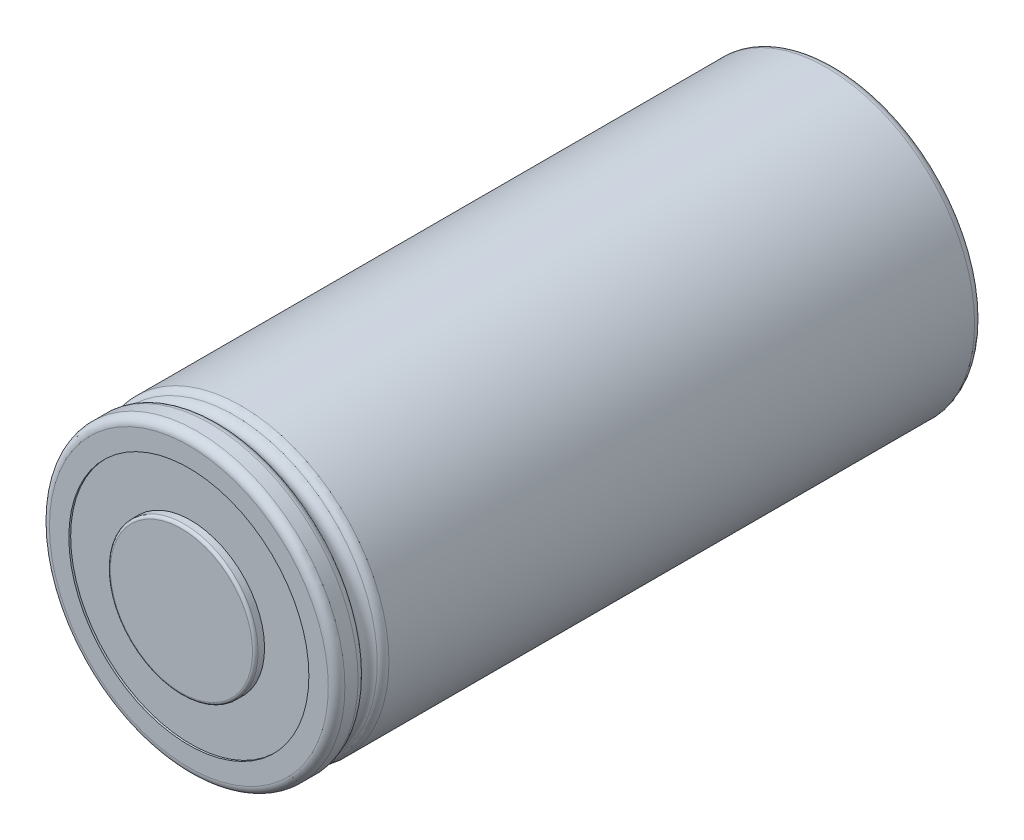
from build123d import *

# Parameters (mm, degrees)
SKETCH2_R           = 13
CUT_EXTRUDE1_DEPTH  = 0.2
SKETCH3_R           = 13
CUT_EXTRUDE2_DEPTH  = 0.2
SKETCH4_R           = 8
BOSS_EXTRUDE1_DEPTH = 1
FILLET1_R           = 0.3
FILLET2_R           = 0.9
BOSS_EXTRUDE2_DEPTH = 0.005


with BuildPart() as part:
    # Sketch1 → Revolve5 (revolve)
    with BuildSketch(Plane(origin=(0, 0, 0), x_dir=(1, 0, 0), z_dir=(0, 1, 0)), mode=Mode.PRIVATE) as revolve5_sk:
        with BuildLine():
            Line((-16, -70), (0, -70))
            Line((0, -70), (0, 0))
            Line((0, 0), (-16, 0))
            Line((-16, 0), (-16, -65))
            ThreePointArc((-16, -65), (-15, -66), (-16, -67))
            Line((-16, -67), (-16, -70))
        make_face()
    revolve(revolve5_sk.sketch.rotate(Axis((0, 0, 70), (0, 0, -1)), 180), axis=Axis((0, 0, 70), (0, 0, -1)))

    # Sketch2 → Cut-Extrude1 (cut)
    with BuildSketch(Plane.XY.offset(70)):
        Circle(SKETCH2_R)
    extrude(amount=-CUT_EXTRUDE1_DEPTH, mode=Mode.SUBTRACT)

    # Sketch3 → Cut-Extrude2 (cut)
    with BuildSketch(Plane(origin=(0, 0, 0), x_dir=(-1, 0, 0), z_dir=(0, 0, -1))):
        with Locations(Location((0, 0, 0), (0, 0, 180))):
            Circle(SKETCH3_R)
    extrude(amount=-CUT_EXTRUDE2_DEPTH, mode=Mode.SUBTRACT)

    # Sketch4 → Boss-Extrude1 (add)
    with BuildSketch(Plane.XY.offset(69.8)):
        Circle(SKETCH4_R)
    extrude(amount=BOSS_EXTRUDE1_DEPTH)

    # Fillet1
    fillet1_edges = [part.edges().sort_by_distance(p)[0] for p in [
        (-8, 0, 70.8),
    ]]
    fillet(fillet1_edges, radius=FILLET1_R)

    # Fillet2
    fillet2_edges = [part.edges().sort_by_distance(p)[0] for p in [
        (-16, 0, 67),
        (-16, 0, 65),
        (-16, 0, 0),
        (-16, 0, 70),
    ]]
    fillet(fillet2_edges, radius=FILLET2_R)

    # Sketch5 → Boss-Extrude2 (add)
    with BuildSketch(Plane(origin=(0, 0, 0.2), x_dir=(-1, 0, 0), z_dir=(0, 0, -1))):
        with BuildLine():
            add(Edge.make_bspline(
                [(12.463312382, 0.467916667), (12.463568751, 0.452915303), (12.464073588, 0.423374981), (12.461600059, 0.379635653), (12.455939689, 0.337394649), (12.447640097, 0.296916367), (12.437129889, 0.25884798), (12.425772381, 0.223332144), (12.413224809, 0.190672648), (12.403315309, 0.170422699), (12.398520715, 0.160625)],
                knots=[0, 0, 0, 0, 1.134571954, 2.234171624, 3.30983776, 4.355420189, 5.356944938, 6.295455342, 7.175276202, 8, 8, 8, 8], degree=3))
            Line((12.398520715, 0.160625), (12.449562382, 0.113958333))
            Line((12.449562382, 0.113958333), (12.451645715, 0.054166667))
            Line((12.451645715, 0.054166667), (12.091437382, 0.031666667))
            Line((12.091437382, 0.031666667), (12.089145715, 0.092083333))
            add(Edge.make_bspline(
                [(12.089145715, 0.092083333), (12.09772169, 0.09597062), (12.115237822, 0.103910269), (12.14143597, 0.117446952), (12.168570709, 0.131846926), (12.195785285, 0.148024142), (12.222680031, 0.165268593), (12.248366514, 0.183789782), (12.272468341, 0.203606103), (12.287358249, 0.217889477), (12.294770715, 0.225)],
                knots=[0, 0, 0, 0, 0.917927946, 1.874836081, 2.874577569, 3.912744782, 4.960757663, 5.988761967, 6.998769181, 8, 8, 8, 8], degree=3))
            add(Edge.make_bspline(
                [(12.294770715, 0.225), (12.302130885, 0.232514924), (12.316719814, 0.247410596), (12.336057478, 0.271811055), (12.35340353, 0.297141085), (12.36841561, 0.32377406), (12.380561834, 0.352073124), (12.388674224, 0.382573519), (12.392832691, 0.415158266), (12.392736689, 0.437489118), (12.392687382, 0.448958333)],
                knots=[0, 0, 0, 0, 0.99993657, 1.982019822, 2.956700106, 3.917788813, 4.885753513, 5.877584783, 6.909919021, 8, 8, 8, 8], degree=3))
            add(Edge.make_bspline(
                [(12.392687382, 0.448958333), (12.392334445, 0.456678119), (12.391644927, 0.47175992), (12.388419083, 0.493539407), (12.384013951, 0.513922037), (12.378602701, 0.532944297), (12.37113521, 0.550391394), (12.362485167, 0.566419038), (12.352326043, 0.580999925), (12.340959022, 0.594092489), (12.32835588, 0.605479666), (12.315239164, 0.61565025), (12.301216402, 0.62396817), (12.286556112, 0.630691623), (12.271187622, 0.635751719), (12.255110085, 0.639048869), (12.238349477, 0.640724554), (12.226996236, 0.640658536), (12.221229048, 0.640625)],
                knots=[0, 0, 0, 0, 1.278933472, 2.498595113, 3.639846239, 4.731350661, 5.767161868, 6.775743304, 7.742281868, 8.703951536, 9.639908856, 10.550662144, 11.447958886, 12.333014638, 13.216649933, 14.120992464, 15.045507072, 16, 16, 16, 16], degree=3))
            add(Edge.make_bspline(
                [(12.221229048, 0.640625), (12.211847888, 0.639775178), (12.193491295, 0.638112289), (12.167419697, 0.628780403), (12.143980894, 0.614052165), (12.123316749, 0.593592177), (12.104814981, 0.567739462), (12.088350519, 0.536159627), (12.073395385, 0.498841319), (12.065304254, 0.471674236), (12.061020715, 0.457291667)],
                knots=[0, 0, 0, 0, 0.859433942, 1.681698007, 2.507101058, 3.374700326, 4.325749461, 5.406370272, 6.626902341, 8, 8, 8, 8], degree=3))
            add(Edge.make_bspline(
                [(12.061020715, 0.457291667), (12.055598462, 0.438195845), (12.045186492, 0.401527486), (12.030248774, 0.348584126), (12.015779081, 0.299467678), (12.005152779, 0.268299938), (11.999979048, 0.253125)],
                knots=[0, 0, 0, 0, 1.117654491, 2.146153079, 3.097399687, 4, 4, 4, 4], degree=3))
            add(Edge.make_bspline(
                [(11.999979048, 0.253125), (11.996908535, 0.244809995), (11.99088796, 0.228506171), (11.979932147, 0.205397056), (11.968077557, 0.183750012), (11.954878544, 0.163767303), (11.940781532, 0.145096195), (11.925301917, 0.128220339), (11.908727727, 0.112878108), (11.89107817, 0.09916171), (11.872491979, 0.087183989), (11.853432643, 0.07637333), (11.833659341, 0.067330085), (11.813341702, 0.059429729), (11.792306112, 0.053523913), (11.770741412, 0.048897304), (11.748602767, 0.045712665), (11.733599778, 0.044823951), (11.726020715, 0.044375)],
                knots=[0, 0, 0, 0, 1.156273794, 2.267188566, 3.334088724, 4.374760002, 5.389860016, 6.384194798, 7.359050151, 8.334368808, 9.297142651, 10.242569349, 11.191421595, 12.132319693, 13.084671418, 14.039219936, 15.009472407, 16, 16, 16, 16], degree=3))
            add(Edge.make_bspline(
                [(11.726020715, 0.044375), (11.716355606, 0.044356354), (11.697153741, 0.044319309), (11.668510255, 0.048303602), (11.640351656, 0.05513549), (11.612752594, 0.065194913), (11.586077817, 0.078341099), (11.560474096, 0.094560098), (11.536060691, 0.113647688), (11.521226012, 0.128385382), (11.513729048, 0.135833333)],
                knots=[0, 0, 0, 0, 0.972689201, 1.932460982, 2.904747538, 3.887399435, 4.885495592, 5.894807761, 6.936104338, 8, 8, 8, 8], degree=3))
            add(Edge.make_bspline(
                [(11.513729048, 0.135833333), (11.506883925, 0.143750212), (11.492826718, 0.160008384), (11.474659247, 0.187742491), (11.458157781, 0.218688784), (11.443273608, 0.252538155), (11.430767118, 0.288932376), (11.421724413, 0.327405733), (11.415276776, 0.367443702), (11.413697709, 0.394837128), (11.412895715, 0.40875)],
                knots=[0, 0, 0, 0, 0.845756185, 1.73685244, 2.674226359, 3.680271448, 4.724721416, 5.781916646, 6.873455654, 8, 8, 8, 8], degree=3))
            add(Edge.make_bspline(
                [(11.412895715, 0.40875), (11.412680789, 0.422366083), (11.412255858, 0.449286496), (11.41535696, 0.489039955), (11.420848228, 0.527652638), (11.429458667, 0.564453078), (11.439605944, 0.598680263), (11.450031726, 0.629504888), (11.46019275, 0.656666606), (11.468126835, 0.672967359), (11.471854048, 0.680625)],
                knots=[0, 0, 0, 0, 1.162942594, 2.29925856, 3.402691885, 4.492271246, 5.524918139, 6.451817781, 7.272706935, 8, 8, 8, 8], degree=3))
            Line((11.471854048, 0.680625), (11.428104048, 0.722083333))
            Line((11.428104048, 0.722083333), (11.425812382, 0.783125))
            Line((11.425812382, 0.783125), (11.765812382, 0.80125))
            Line((11.765812382, 0.80125), (11.768104048, 0.740833333))
            add(Edge.make_bspline(
                [(11.768104048, 0.740833333), (11.749826312, 0.732675486), (11.712485565, 0.716009301), (11.667018573, 0.692380769), (11.63136483, 0.672220324), (11.606849372, 0.656386459), (11.5846063, 0.640464315), (11.571226352, 0.629049267), (11.564770715, 0.623541667)],
                knots=[0, 0, 0, 0, 1.528819092, 3.123321518, 3.912299851, 4.656920509, 5.35198303, 6, 6, 6, 6], degree=3))
            add(Edge.make_bspline(
                [(11.564770715, 0.623541667), (11.558392223, 0.617484591), (11.545716376, 0.605447488), (11.52913911, 0.585382537), (11.514680968, 0.564117396), (11.502001469, 0.541865046), (11.491943466, 0.517896728), (11.485693236, 0.491950479), (11.481965345, 0.464277437), (11.482166982, 0.44522056), (11.482270715, 0.435416667)],
                knots=[0, 0, 0, 0, 0.991968688, 1.971318973, 2.929942269, 3.891348593, 4.857725105, 5.851827628, 6.894863428, 8, 8, 8, 8], degree=3))
            add(Edge.make_bspline(
                [(11.482270715, 0.435416667), (11.482574999, 0.429225833), (11.483172605, 0.4170672), (11.485961501, 0.399376691), (11.489931383, 0.382592518), (11.495042009, 0.366688204), (11.501828954, 0.351820259), (11.509760469, 0.337795706), (11.518916572, 0.324638648), (11.529320402, 0.312559546), (11.540750364, 0.30180731), (11.552803751, 0.292316045), (11.56561354, 0.284651857), (11.578888775, 0.278229948), (11.592833935, 0.273531078), (11.607258218, 0.270113217), (11.62229962, 0.26843728), (11.632475736, 0.268506312), (11.637687382, 0.268541667)],
                knots=[0, 0, 0, 0, 1.165950123, 2.289895012, 3.364653197, 4.410406409, 5.42834293, 6.435141217, 7.439560969, 8.440487669, 9.429825701, 10.38935753, 11.321890477, 12.233954197, 13.159868135, 14.08568981, 15.019595813, 16, 16, 16, 16], degree=3))
            add(Edge.make_bspline(
                [(11.637687382, 0.268541667), (11.647219752, 0.269278165), (11.6657488, 0.270709773), (11.691666849, 0.280267009), (11.715096194, 0.294026876), (11.7349627, 0.314226636), (11.752798835, 0.339346873), (11.768835812, 0.370076601), (11.783670527, 0.406349201), (11.791605965, 0.432835266), (11.795812382, 0.446875)],
                knots=[0, 0, 0, 0, 0.888352215, 1.726781609, 2.552691153, 3.405207355, 4.347801002, 5.420690197, 6.63275937, 8, 8, 8, 8], degree=3))
            add(Edge.make_bspline(
                [(11.795812382, 0.446875), (11.801155656, 0.464564407), (11.81192737, 0.500225174), (11.826730195, 0.553497611), (11.841633873, 0.604226031), (11.852264803, 0.636620861), (11.857270715, 0.651875)],
                knots=[0, 0, 0, 0, 1.03600687, 2.088526787, 3.099921833, 4, 4, 4, 4], degree=3))
            add(Edge.make_bspline(
                [(11.857270715, 0.651875), (11.860305301, 0.660243223), (11.866287405, 0.676739571), (11.876649435, 0.700434408), (11.888189029, 0.722561419), (11.900457513, 0.743295504), (11.913741482, 0.762514244), (11.928284821, 0.780097915), (11.943582608, 0.796343261), (11.95997671, 0.811020392), (11.977291814, 0.824280156), (11.995893838, 0.835716792), (12.01564509, 0.845560347), (12.036408246, 0.853853766), (12.058273686, 0.860598838), (12.081210208, 0.865540048), (12.105311722, 0.868895216), (12.121774702, 0.869902129), (12.130187382, 0.870416667)],
                knots=[0, 0, 0, 0, 1.138647468, 2.244625243, 3.305615964, 4.329541404, 5.325248072, 6.291054771, 7.246301398, 8.177445417, 9.103233347, 10.032765288, 10.966491296, 11.923389171, 12.890135312, 13.89042942, 14.921996918, 16, 16, 16, 16], degree=3))
            add(Edge.make_bspline(
                [(12.130187382, 0.870416667), (12.140892258, 0.870371929), (12.162328592, 0.870282341), (12.194381837, 0.865931015), (12.225847224, 0.857051429), (12.25671611, 0.845163549), (12.286039212, 0.829775176), (12.313495338, 0.811769734), (12.338377718, 0.790798164), (12.352796343, 0.774690684), (12.359979048, 0.766666667)],
                knots=[0, 0, 0, 0, 0.985227095, 1.972900521, 2.967403997, 3.989971709, 5.014038276, 6.010903777, 7.009122351, 8, 8, 8, 8], degree=3))
            add(Edge.make_bspline(
                [(12.359979048, 0.766666667), (12.367558554, 0.757379755), (12.382821501, 0.738678582), (12.401890447, 0.707491002), (12.419277844, 0.674520702), (12.433526944, 0.638852192), (12.445567206, 0.600594779), (12.454684726, 0.559275425), (12.460666394, 0.514665008), (12.462411292, 0.483836798), (12.463312382, 0.467916667)],
                knots=[0, 0, 0, 0, 0.891815346, 1.795859848, 2.716543208, 3.665456185, 4.65185477, 5.700901956, 6.812712692, 8, 8, 8, 8], degree=3))
        make_face()
        with BuildLine():
            Line((12.22227405, 2.399631339), (12.301857383, 1.861089673))
            Line((12.301857383, 1.861089673), (12.247482383, 1.852964673))
            add(Edge.make_bspline(
                [(12.247482383, 1.852964673), (12.245945591, 1.859508483), (12.242755331, 1.873092924), (12.236539397, 1.894029857), (12.229322116, 1.916440657), (12.22114418, 1.938998316), (12.213182593, 1.959594318), (12.204499871, 1.97446392), (12.196229086, 1.985019171), (12.18928605, 1.986074042), (12.186440717, 1.986506339)],
                knots=[0, 0, 0, 0, 1.063550276, 2.2078474, 3.455557658, 4.787001278, 6.013672841, 6.920278026, 7.557517966, 8, 8, 8, 8], degree=3))
            add(Edge.make_bspline(
                [(12.186440717, 1.986506339), (12.184487256, 1.986200911), (12.180316801, 1.98554885), (12.173608651, 1.983520864), (12.165372206, 1.980194229), (12.159592924, 1.976940175), (12.156232383, 1.975048006)],
                knots=[0, 0, 0, 0, 0.728751773, 1.555815975, 2.57875447, 4, 4, 4, 4], degree=3))
            Line((12.156232383, 1.975048006), (11.963940717, 1.860256339))
            Line((11.963940717, 1.860256339), (12.014357383, 1.519006339))
            add(Edge.make_bspline(
                [(12.014357383, 1.519006339), (12.025256489, 1.516421615), (12.048761521, 1.510847395), (12.085040704, 1.502590836), (12.121693548, 1.495131317), (12.14567504, 1.490385797), (12.156857383, 1.488173006)],
                knots=[0, 0, 0, 0, 0.921859099, 1.988082994, 3.06186209, 4, 4, 4, 4], degree=3))
            add(Edge.make_bspline(
                [(12.156857383, 1.488173006), (12.163239906, 1.487025301), (12.174938757, 1.484921614), (12.191119409, 1.482535232), (12.204335633, 1.481269657), (12.217271443, 1.480696249), (12.228953769, 1.481128631), (12.237205779, 1.481701373), (12.24039905, 1.481923006)],
                knots=[0, 0, 0, 0, 1.38818836, 2.544481218, 3.500068393, 4.229102248, 5.314717529, 6, 6, 6, 6], degree=3))
            add(Edge.make_bspline(
                [(12.24039905, 1.481923006), (12.244001837, 1.482914802), (12.251450534, 1.484965322), (12.260768185, 1.493616839), (12.268174389, 1.505968921), (12.274166277, 1.522507781), (12.278369294, 1.543752681), (12.280603262, 1.57013335), (12.281192414, 1.601870294), (12.280000478, 1.624773955), (12.279357383, 1.637131339)],
                knots=[0, 0, 0, 0, 0.519412252, 1.073875627, 1.732817016, 2.537035736, 3.535772166, 4.772890092, 6.258853118, 8, 8, 8, 8], degree=3))
            Line((12.279357383, 1.637131339), (12.333732383, 1.645256339))
            Line((12.333732383, 1.645256339), (12.393732383, 1.239839673))
            Line((12.393732383, 1.239839673), (12.339357383, 1.231714673))
            add(Edge.make_bspline(
                [(12.339357383, 1.231714673), (12.337399084, 1.239806825), (12.33323384, 1.25701859), (12.325791115, 1.278240243), (12.319328262, 1.295555783), (12.31361516, 1.30717835), (12.30795816, 1.317458446), (12.303262246, 1.323162593), (12.30102405, 1.325881339)],
                knots=[0, 0, 0, 0, 1.461471495, 3.108505972, 3.946595905, 4.704908682, 5.38272539, 6, 6, 6, 6], degree=3))
            add(Edge.make_bspline(
                [(12.30102405, 1.325881339), (12.293806746, 1.33403078), (12.279552211, 1.350126331), (12.253110222, 1.369034565), (12.2233875, 1.383890238), (12.201647386, 1.389733194), (12.19039905, 1.392756339)],
                knots=[0, 0, 0, 0, 0.989094179, 1.953510397, 2.941146152, 4, 4, 4, 4], degree=3))
            add(Edge.make_bspline(
                [(12.19039905, 1.392756339), (12.121018207, 1.410024644), (11.982174818, 1.444581588), (11.807789435, 1.488359292), (11.665269321, 1.52369684), (11.55317458, 1.552329448), (11.435477998, 1.581406483), (11.355318685, 1.601740622), (11.314357383, 1.612131339)],
                knots=[0, 0, 0, 0, 1.425053589, 2.85178533, 3.583614864, 4.351702734, 5.157722312, 6, 6, 6, 6], degree=3))
            Line((11.314357383, 1.612131339), (11.293732383, 1.751298006))
            add(Edge.make_bspline(
                [(11.293732383, 1.751298006), (11.319367386, 1.766350466), (11.369271108, 1.795653127), (11.441850738, 1.83864953), (11.510557811, 1.87883365), (11.574950063, 1.916700279), (11.635274032, 1.95201838), (11.69156243, 1.984611028), (11.743512361, 2.015118165), (11.79193482, 2.043020311), (11.837249307, 2.06920721), (11.880185595, 2.094292698), (11.921269755, 2.11813043), (11.960106118, 2.141323752), (11.997077975, 2.163221613), (12.032141973, 2.184018081), (12.065116014, 2.204015125), (12.086508043, 2.216926539), (12.096857383, 2.223173006)],
                knots=[0, 0, 0, 0, 1.531851933, 2.982059942, 4.346993053, 5.633364487, 6.831380805, 7.949031797, 8.985028237, 9.935771621, 10.828815064, 11.681928044, 12.498206631, 13.276385537, 14.012833412, 14.712454455, 15.377092904, 16, 16, 16, 16], degree=3))
            add(Edge.make_bspline(
                [(12.096857383, 2.223173006), (12.103183971, 2.227357806), (12.11570677, 2.235641166), (12.129289037, 2.248862247), (12.139086283, 2.260794176), (12.14595533, 2.271249968), (12.152192492, 2.283228159), (12.155809094, 2.291825195), (12.157690717, 2.296298006)],
                knots=[0, 0, 0, 0, 1.405602407, 2.782238684, 3.496938214, 4.269188885, 5.099504647, 6, 6, 6, 6], degree=3))
            add(Edge.make_bspline(
                [(12.157690717, 2.296298006), (12.160263935, 2.303731592), (12.165595685, 2.319134105), (12.168183509, 2.3438038), (12.169090352, 2.368104295), (12.168280851, 2.384006199), (12.16789905, 2.391506339)],
                knots=[0, 0, 0, 0, 0.97535349, 2.020948714, 3.066579609, 4, 4, 4, 4], degree=3))
            Line((12.16789905, 2.391506339), (12.22227405, 2.399631339))
        make_face()
        Polygon((11.89914905, 1.821714673), (11.56227405, 1.625256339), (11.941232383, 1.536714673), align=None, mode=Mode.SUBTRACT)
        with BuildLine():
            Line((12.012748507, 3.280964655), (12.14670684, 2.743047988))
            Line((12.14670684, 2.743047988), (12.093373507, 2.729714655))
            add(Edge.make_bspline(
                [(12.093373507, 2.729714655), (12.092267171, 2.733049597), (12.089798642, 2.74049074), (12.085622483, 2.752686351), (12.080837028, 2.767063908), (12.075719552, 2.782810969), (12.070458674, 2.798220685), (12.065323547, 2.81162438), (12.060479314, 2.82214729), (12.056826633, 2.827868032), (12.055248507, 2.830339655)],
                knots=[0, 0, 0, 0, 0.781869314, 1.744558309, 2.868495447, 4.153702422, 5.42921099, 6.490982789, 7.348035142, 8, 8, 8, 8], degree=3))
            add(Edge.make_bspline(
                [(12.055248507, 2.830339655), (12.052575357, 2.833902007), (12.047509448, 2.840653052), (12.038654453, 2.848917186), (12.029426374, 2.854943456), (12.019646782, 2.85853698), (12.00950019, 2.860472805), (11.998559286, 2.860469481), (11.98680524, 2.859550115), (11.97877383, 2.857735639), (11.974623507, 2.856797988)],
                knots=[0, 0, 0, 0, 1.164582335, 2.207010068, 3.155565514, 4.030468598, 4.918692511, 5.846444547, 6.887125503, 8, 8, 8, 8], degree=3))
            Line((11.974623507, 2.856797988), (11.286915173, 2.685339655))
            add(Edge.make_bspline(
                [(11.286915173, 2.685339655), (11.279693831, 2.68310111), (11.265790185, 2.678791118), (11.250489532, 2.668907336), (11.240536239, 2.658751008), (11.235048799, 2.648845365), (11.230562637, 2.637296391), (11.228992274, 2.628782303), (11.228165173, 2.624297988)],
                knots=[0, 0, 0, 0, 1.492653451, 2.873887339, 3.555088925, 4.288853182, 5.098750007, 6, 6, 6, 6], degree=3))
            add(Edge.make_bspline(
                [(11.228165173, 2.624297988), (11.227799312, 2.620966657), (11.226992702, 2.61362212), (11.226121077, 2.601604532), (11.226036897, 2.587560419), (11.226300063, 2.567065337), (11.227383479, 2.542446897), (11.229208697, 2.523250994), (11.230040173, 2.514506322)],
                knots=[0, 0, 0, 0, 0.548350956, 1.208941283, 1.970313511, 2.845299718, 4.562879671, 6, 6, 6, 6], degree=3))
            Line((11.230040173, 2.514506322), (11.17670684, 2.501172988))
            Line((11.17670684, 2.501172988), (11.042748507, 3.039089655))
            Line((11.042748507, 3.039089655), (11.09608184, 3.052422988))
            add(Edge.make_bspline(
                [(11.09608184, 3.052422988), (11.098771999, 3.044915685), (11.104769097, 3.02817986), (11.114503209, 3.002358703), (11.125092964, 2.976455637), (11.134060568, 2.960683704), (11.138165173, 2.953464655)],
                knots=[0, 0, 0, 0, 0.888400635, 1.980487188, 3.075638946, 4, 4, 4, 4], degree=3))
            add(Edge.make_bspline(
                [(11.138165173, 2.953464655), (11.140754744, 2.949691741), (11.145654137, 2.942553497), (11.15445755, 2.933790441), (11.164161683, 2.927688179), (11.178091875, 2.923002186), (11.197111141, 2.921916431), (11.211960384, 2.92486149), (11.219623507, 2.926381322)],
                knots=[0, 0, 0, 0, 0.883335966, 1.671245904, 2.38271794, 3.078956553, 4.492561828, 6, 6, 6, 6], degree=3))
            Line((11.219623507, 2.926381322), (11.906498507, 3.097631322))
            add(Edge.make_bspline(
                [(11.906498507, 3.097631322), (11.914063446, 3.099910348), (11.928354406, 3.104215665), (11.944222157, 3.114287859), (11.95355038, 3.125111563), (11.959331332, 3.134935343), (11.963359094, 3.146721345), (11.965008754, 3.155246017), (11.965873507, 3.159714655)],
                knots=[0, 0, 0, 0, 1.537374138, 2.904260112, 3.585688425, 4.307865529, 5.112981993, 6, 6, 6, 6], degree=3))
            add(Edge.make_bspline(
                [(11.965873507, 3.159714655), (11.966265829, 3.16276606), (11.967145741, 3.169609836), (11.967477562, 3.181107808), (11.966895776, 3.194859014), (11.965900115, 3.215373946), (11.963709348, 3.23995515), (11.960749503, 3.259031501), (11.959415173, 3.267631322)],
                knots=[0, 0, 0, 0, 0.510570289, 1.145121063, 1.90642835, 2.795409744, 4.55533694, 6, 6, 6, 6], degree=3))
            Line((11.959415173, 3.267631322), (12.012748507, 3.280964655))
        make_face()
        with BuildLine():
            Line((11.485892443, 4.770230779), (11.620475777, 4.412522445))
            add(Edge.make_bspline(
                [(11.620475777, 4.412522445), (11.611788209, 4.400652577), (11.594790026, 4.377427872), (11.57009013, 4.343433577), (11.546912957, 4.311059122), (11.525195668, 4.280350727), (11.504821993, 4.251271394), (11.485890754, 4.223868325), (11.468512974, 4.198067267), (11.446713163, 4.165281933), (11.419539865, 4.122986765), (11.386382949, 4.068841309), (11.351030656, 4.009821813), (11.327350397, 3.968535515), (11.31505911, 3.947105779)],
                knots=[0, 0, 0, 0, 0.950569826, 1.859894457, 2.715460737, 3.523561172, 4.290474912, 5.009980469, 5.675888545, 6.300713334, 7.554273029, 8.924313211, 10.403558564, 12, 12, 12, 12], degree=3))
            Line((11.31505911, 3.947105779), (11.328600777, 3.911064112))
            Line((11.328600777, 3.911064112), (11.61193411, 4.017730779))
            add(Edge.make_bspline(
                [(11.61193411, 4.017730779), (11.615726965, 4.019234464), (11.623022477, 4.022126784), (11.632947285, 4.027846817), (11.641492595, 4.034349069), (11.649065956, 4.041455702), (11.655156618, 4.050106894), (11.659357126, 4.060530547), (11.662654506, 4.072545097), (11.663273128, 4.081246911), (11.663600777, 4.085855779)],
                knots=[0, 0, 0, 0, 1.065855875, 2.050161045, 2.983566375, 3.869668072, 4.756327825, 5.724418211, 6.79475087, 8, 8, 8, 8], degree=3))
            add(Edge.make_bspline(
                [(11.663600777, 4.085855779), (11.663631834, 4.088564499), (11.663701191, 4.094613535), (11.663049741, 4.104572734), (11.661417578, 4.116278224), (11.659123502, 4.133552401), (11.655539951, 4.154299297), (11.651921146, 4.170381583), (11.650267443, 4.177730779)],
                knots=[0, 0, 0, 0, 0.524067235, 1.170331612, 1.928694583, 2.810472897, 4.542467099, 6, 6, 6, 6], degree=3))
            Line((11.650267443, 4.177730779), (11.701517443, 4.196897445))
            Line((11.701517443, 4.196897445), (11.888600777, 3.699189112))
            Line((11.888600777, 3.699189112), (11.837350777, 3.680022445))
            add(Edge.make_bspline(
                [(11.837350777, 3.680022445), (11.835672729, 3.683280551), (11.832074951, 3.690266017), (11.826539337, 3.701632547), (11.819754939, 3.714209103), (11.812860117, 3.727847908), (11.805923651, 3.741057612), (11.79930836, 3.752604117), (11.79320562, 3.761758502), (11.788984457, 3.766786626), (11.787142443, 3.768980779)],
                knots=[0, 0, 0, 0, 0.859264669, 1.842286406, 2.963872105, 4.209118135, 5.425501203, 6.461569163, 7.328665733, 8, 8, 8, 8], degree=3))
            add(Edge.make_bspline(
                [(11.787142443, 3.768980779), (11.783962077, 3.772194855), (11.777946442, 3.778274252), (11.768119944, 3.785557757), (11.758098553, 3.790221158), (11.748060844, 3.792939674), (11.737678841, 3.793065076), (11.726820151, 3.79236486), (11.715296536, 3.789730655), (11.707602947, 3.787044678), (11.703600777, 3.785647445)],
                knots=[0, 0, 0, 0, 1.180389296, 2.232696079, 3.174082679, 4.05403836, 4.925539055, 5.871633054, 6.892833404, 8, 8, 8, 8], degree=3))
            Line((11.703600777, 3.785647445), (11.045475777, 3.538147445))
            add(Edge.make_bspline(
                [(11.045475777, 3.538147445), (11.038330666, 3.535088784), (11.025076976, 3.529415177), (11.010516037, 3.519002948), (11.002121635, 3.50827027), (10.998149031, 3.497777946), (10.995197517, 3.485175145), (10.994566535, 3.475877119), (10.994225777, 3.470855779)],
                knots=[0, 0, 0, 0, 1.525657091, 2.829989189, 3.463037856, 4.172482359, 5.013060681, 6, 6, 6, 6], degree=3))
            add(Edge.make_bspline(
                [(10.994225777, 3.470855779), (10.994349752, 3.462234923), (10.994614536, 3.443822578), (10.997617742, 3.420655479), (11.000509016, 3.401799014), (11.002956169, 3.388931947), (11.004666403, 3.377628054), (11.006075714, 3.370712386), (11.006725777, 3.367522445)],
                knots=[0, 0, 0, 0, 1.487524147, 3.17704042, 4.026634754, 4.781619354, 5.438006199, 6, 6, 6, 6], degree=3))
            Line((11.006725777, 3.367522445), (10.955475777, 3.348355779))
            Line((10.955475777, 3.348355779), (10.75880911, 3.871689112))
            add(Edge.make_bspline(
                [(10.75880911, 3.871689112), (10.753585513, 3.885942793), (10.743469694, 3.91354593), (10.731269849, 3.954573797), (10.721332634, 3.993459332), (10.714187288, 4.03046096), (10.709633495, 4.065457913), (10.708223679, 4.098487209), (10.709124421, 4.129505487), (10.71275341, 4.158583413), (10.719395163, 4.185583323), (10.728847299, 4.210414126), (10.740875735, 4.233250072), (10.756362486, 4.253556553), (10.774427127, 4.271837572), (10.795251555, 4.288003393), (10.818986998, 4.301917388), (10.836345366, 4.308922082), (10.845267443, 4.312522445)],
                knots=[0, 0, 0, 0, 1.437725212, 2.784244136, 4.052666846, 5.238333029, 6.35210676, 7.392515255, 8.36667552, 9.288709687, 10.163044596, 10.993827836, 11.800266963, 12.598887132, 13.403634117, 14.228693787, 15.089561239, 16, 16, 16, 16], degree=3))
            add(Edge.make_bspline(
                [(10.845267443, 4.312522445), (10.853277302, 4.31537989), (10.868970271, 4.320978214), (10.892796154, 4.326679729), (10.915968553, 4.330579583), (10.938656739, 4.332082101), (10.960772014, 4.331199659), (10.982435885, 4.32834749), (11.003491491, 4.323054936), (11.024123054, 4.315758275), (11.044236601, 4.305954856), (11.064265882, 4.294220284), (11.084326321, 4.280544925), (11.103888552, 4.264266223), (11.123500462, 4.246114966), (11.143052559, 4.225887721), (11.162543218, 4.203562083), (11.174804694, 4.187458208), (11.181100777, 4.179189112)],
                knots=[0, 0, 0, 0, 1.03672258, 2.031153802, 2.983751569, 3.900571855, 4.799168938, 5.679736186, 6.561158729, 7.44270339, 8.344489259, 9.28598592, 10.272883463, 11.302242468, 12.387263758, 13.531516802, 14.732471329, 16, 16, 16, 16], degree=3))
            add(Edge.make_bspline(
                [(11.181100777, 4.179189112), (11.188267098, 4.190708531), (11.203140407, 4.214616458), (11.226008359, 4.251981017), (11.25063681, 4.291910832), (11.285617343, 4.349422991), (11.331168321, 4.424246201), (11.367213872, 4.485326888), (11.385475777, 4.516272445)],
                knots=[0, 0, 0, 0, 0.619462815, 1.285661379, 2.000261629, 2.761607968, 4.359320213, 6, 6, 6, 6], degree=3))
            add(Edge.make_bspline(
                [(11.385475777, 4.516272445), (11.388633954, 4.521670428), (11.395338506, 4.533129901), (11.40531204, 4.551801791), (11.41605952, 4.572821161), (11.427462797, 4.595249357), (11.437720128, 4.617735826), (11.444843933, 4.638876765), (11.449336262, 4.657605554), (11.44954571, 4.669377323), (11.449642443, 4.674814112)],
                knots=[0, 0, 0, 0, 0.868753728, 1.844292848, 2.940246115, 4.148299316, 5.340414799, 6.368537253, 7.246509209, 8, 8, 8, 8], degree=3))
            add(Edge.make_bspline(
                [(11.449642443, 4.674814112), (11.449059809, 4.681080473), (11.447762959, 4.695028387), (11.443977921, 4.712560772), (11.440854928, 4.727127715), (11.438604562, 4.736725748), (11.436460265, 4.744470344), (11.435197665, 4.749050164), (11.434642443, 4.751064112)],
                knots=[0, 0, 0, 0, 1.454447026, 3.237365906, 4.141540087, 4.901208334, 5.516812966, 6, 6, 6, 6], degree=3))
            Line((11.434642443, 4.751064112), (11.485892443, 4.770230779))
        make_face()
        with BuildLine():
            add(Edge.make_bspline(
                [(10.960475777, 4.061689112), (10.952997509, 4.058673606), (10.938575401, 4.052858096), (10.918351725, 4.042611797), (10.900398703, 4.031188765), (10.884606127, 4.018615733), (10.871035181, 4.005013126), (10.859315869, 3.990572108), (10.850087909, 3.974820959), (10.843300033, 3.957984114), (10.838162168, 3.940409339), (10.835416506, 3.921848344), (10.834021514, 3.902465225), (10.835078744, 3.882180394), (10.83751175, 3.861063385), (10.842023577, 3.839081603), (10.848219506, 3.816161903), (10.85370106, 3.800821105), (10.856517443, 3.792939112)],
                knots=[0, 0, 0, 0, 1.171256336, 2.258809951, 3.288860124, 4.258000905, 5.185539599, 6.075889842, 6.953281095, 7.826484855, 8.707985962, 9.60709825, 10.547446223, 11.527036264, 12.553323504, 13.633785884, 14.784256042, 16, 16, 16, 16], degree=3))
            Line((10.856517443, 3.792939112), (10.876100777, 3.741064112))
            Line((10.876100777, 3.741064112), (11.266725777, 3.887939112))
            Line((11.266725777, 3.887939112), (11.247975777, 3.937939112))
            add(Edge.make_bspline(
                [(11.247975777, 3.937939112), (11.244917507, 3.945708776), (11.23894513, 3.960881853), (11.227930842, 3.982048473), (11.216439659, 4.001637348), (11.203370685, 4.018967372), (11.189468737, 4.03450298), (11.174326836, 4.047933426), (11.158194132, 4.059445081), (11.141054278, 4.069217169), (11.122593181, 4.076477827), (11.102939105, 4.081558895), (11.08208618, 4.084169858), (11.060015529, 4.084593282), (11.036763768, 4.082435931), (11.012382056, 4.077621437), (10.986606741, 4.071095574), (10.969386657, 4.064896795), (10.960475777, 4.061689112)],
                knots=[0, 0, 0, 0, 1.116341705, 2.180060635, 3.188671088, 4.151212085, 5.078676644, 5.973696478, 6.852855053, 7.726399091, 8.606293754, 9.498657379, 10.435567208, 11.411290652, 12.446759296, 13.552847002, 14.733671264, 16, 16, 16, 16], degree=3))
        make_face(mode=Mode.SUBTRACT)
        with BuildLine():
            add(Edge.make_bspline(
                [(10.013032184, 5.718438036), (10.015022052, 5.715228062), (10.019407299, 5.708153962), (10.027169628, 5.69692849), (10.036665828, 5.684079775), (10.046938045, 5.669608062), (10.058571932, 5.655425105), (10.071182319, 5.642781708), (10.084278631, 5.632027517), (10.093658918, 5.626256678), (10.098240517, 5.623438036)],
                knots=[0, 0, 0, 0, 0.70317892, 1.549656762, 2.540311305, 3.678333919, 4.853868298, 5.95112042, 6.999269037, 8, 8, 8, 8], degree=3))
            add(Edge.make_bspline(
                [(10.098240517, 5.623438036), (10.10308421, 5.621031466), (10.113139727, 5.61603542), (10.130851726, 5.613318603), (10.150516128, 5.613354432), (10.172841929, 5.617067823), (10.198469384, 5.624247203), (10.228117824, 5.635341096), (10.262450695, 5.649800838), (10.286551625, 5.661249831), (10.299490517, 5.66739637)],
                knots=[0, 0, 0, 0, 0.606552443, 1.259204208, 1.995154047, 2.818976074, 3.800915555, 4.992223387, 6.38523661, 8, 8, 8, 8], degree=3))
            Line((10.299490517, 5.66739637), (10.632823851, 5.829063036))
            add(Edge.make_bspline(
                [(10.632823851, 5.829063036), (10.644950532, 5.834576579), (10.668659276, 5.845356048), (10.7051855, 5.857248445), (10.741391528, 5.865267563), (10.77743822, 5.869376909), (10.813209127, 5.869020243), (10.84873677, 5.865180646), (10.883851995, 5.856891323), (10.91843097, 5.844834637), (10.951825028, 5.828915776), (10.983960315, 5.80999927), (11.014010637, 5.787291388), (11.042332858, 5.761329198), (11.068517746, 5.731801213), (11.093015368, 5.699040106), (11.115822351, 5.662994502), (11.129002925, 5.637094275), (11.135740517, 5.623854703)],
                knots=[0, 0, 0, 0, 1.044692871, 2.042467681, 3.007687358, 3.950684336, 4.8825465, 5.809295878, 6.749138484, 7.707364338, 8.677555295, 9.647639117, 10.628529885, 11.627435015, 12.657889182, 13.720520848, 14.834785172, 16, 16, 16, 16], degree=3))
            add(Edge.make_bspline(
                [(11.135740517, 5.623854703), (11.143059269, 5.608260399), (11.157308137, 5.577899871), (11.174211411, 5.531888237), (11.187815013, 5.487521299), (11.197143177, 5.444386957), (11.20207947, 5.40260282), (11.203578009, 5.362217563), (11.20061191, 5.323172264), (11.193729738, 5.285689672), (11.183309783, 5.249910817), (11.168363822, 5.21652241), (11.150383278, 5.185067363), (11.128132693, 5.156128745), (11.102482332, 5.129270618), (11.072631916, 5.105145049), (11.039589856, 5.08255809), (11.015269853, 5.070186161), (11.002823851, 5.063854703)],
                knots=[0, 0, 0, 0, 1.266893255, 2.466512589, 3.602888716, 4.679174482, 5.708393282, 6.69499114, 7.64803479, 8.58306186, 9.494806594, 10.382452812, 11.268450497, 12.154448182, 13.061470492, 13.994373196, 14.9736006, 16, 16, 16, 16], degree=3))
            Line((11.002823851, 5.063854703), (10.544282184, 4.84114637))
            add(Edge.make_bspline(
                [(10.544282184, 4.84114637), (10.537614117, 4.83743473), (10.524879013, 4.830346003), (10.511982964, 4.817316411), (10.505100924, 4.804926074), (10.501420471, 4.794134242), (10.498908889, 4.781668463), (10.498336386, 4.77275668), (10.498032184, 4.76802137)],
                knots=[0, 0, 0, 0, 1.490775306, 2.84717863, 3.51697428, 4.252587265, 5.071505341, 6, 6, 6, 6], degree=3))
            add(Edge.make_bspline(
                [(10.498032184, 4.76802137), (10.498328249, 4.760708294), (10.498968072, 4.744904135), (10.504000214, 4.721279928), (10.510154243, 4.6988379), (10.514464636, 4.684681153), (10.516365517, 4.678438036)],
                knots=[0, 0, 0, 0, 0.955610719, 2.065153654, 3.146733861, 4, 4, 4, 4], degree=3))
            Line((10.516365517, 4.678438036), (10.468448851, 4.655313036))
            Line((10.468448851, 4.655313036), (10.240323851, 5.125104703))
            Line((10.240323851, 5.125104703), (10.288240517, 5.148229703))
            add(Edge.make_bspline(
                [(10.288240517, 5.148229703), (10.292076218, 5.141738944), (10.299861157, 5.1285653), (10.312672097, 5.109182579), (10.327333285, 5.090275681), (10.338288106, 5.078428239), (10.343865517, 5.07239637)],
                knots=[0, 0, 0, 0, 0.959409328, 1.947217269, 2.954869845, 4, 4, 4, 4], degree=3))
            add(Edge.make_bspline(
                [(10.343865517, 5.07239637), (10.347018617, 5.069275424), (10.352973457, 5.06338131), (10.363267735, 5.056963679), (10.373836939, 5.052950644), (10.388518096, 5.051864647), (10.4073425, 5.054501187), (10.421402029, 5.060396085), (10.428657184, 5.063438036)],
                knots=[0, 0, 0, 0, 0.861681571, 1.627343472, 2.346168401, 3.039335824, 4.472205081, 6, 6, 6, 6], degree=3))
            Line((10.428657184, 5.063438036), (10.880740517, 5.28302137))
            add(Edge.make_bspline(
                [(10.880740517, 5.28302137), (10.891361393, 5.288455921), (10.911939677, 5.298985536), (10.940681859, 5.316211715), (10.966298815, 5.334166829), (10.988765925, 5.352838699), (11.007791162, 5.372609289), (11.024039763, 5.392738747), (11.036935299, 5.413814349), (11.046616407, 5.435691783), (11.053265065, 5.458334955), (11.057260537, 5.481617863), (11.058482781, 5.505597507), (11.056974956, 5.530323842), (11.052682166, 5.555756243), (11.045998508, 5.582005945), (11.036371318, 5.608898213), (11.028108753, 5.626625742), (11.023865517, 5.635729703)],
                knots=[0, 0, 0, 0, 1.309174835, 2.536567656, 3.67423369, 4.739895671, 5.73706985, 6.681003711, 7.573795281, 8.440537691, 9.299064346, 10.157387985, 11.027475094, 11.928427872, 12.870698629, 13.854146344, 14.897998248, 16, 16, 16, 16], degree=3))
            add(Edge.make_bspline(
                [(11.023865517, 5.635729703), (11.019370832, 5.644568289), (11.010595456, 5.661824655), (10.995064695, 5.685661523), (10.97817489, 5.706999537), (10.959981196, 5.725863117), (10.940474844, 5.742377227), (10.919344629, 5.7560943), (10.896925466, 5.767424595), (10.873258957, 5.776243598), (10.848375272, 5.782311862), (10.822360359, 5.78541265), (10.795327504, 5.785562398), (10.767272, 5.782794355), (10.738250812, 5.77699592), (10.708160168, 5.76872004), (10.677165766, 5.757077343), (10.656582646, 5.747534693), (10.645948851, 5.742604703)],
                knots=[0, 0, 0, 0, 1.064377944, 2.078080682, 3.049553361, 3.98318229, 4.888496326, 5.788386688, 6.682322786, 7.581471021, 8.495012435, 9.426613288, 10.388793494, 11.392929794, 12.449043911, 13.563739699, 14.741362181, 16, 16, 16, 16], degree=3))
            Line((10.645948851, 5.742604703), (10.342198851, 5.595104703))
            add(Edge.make_bspline(
                [(10.342198851, 5.595104703), (10.329628055, 5.588919523), (10.306087586, 5.57733696), (10.274302237, 5.559217188), (10.247979302, 5.542551583), (10.227296457, 5.526464378), (10.211060273, 5.510988883), (10.198936389, 5.495428762), (10.189543403, 5.479978851), (10.186552893, 5.468948204), (10.185115517, 5.46364637)],
                knots=[0, 0, 0, 0, 1.593806749, 2.984612697, 4.161620537, 5.135370042, 5.96240948, 6.705370423, 7.377741673, 8, 8, 8, 8], degree=3))
            add(Edge.make_bspline(
                [(10.185115517, 5.46364637), (10.184284828, 5.459284917), (10.182464342, 5.449726633), (10.18270004, 5.433605359), (10.184077751, 5.414733906), (10.187543308, 5.394148933), (10.191279128, 5.37388047), (10.195010756, 5.35610881), (10.198257875, 5.341843571), (10.200575328, 5.333639569), (10.201573851, 5.330104703)],
                knots=[0, 0, 0, 0, 0.78430826, 1.718840154, 2.8410277, 4.134794441, 5.410498569, 6.490816524, 7.3497368, 8, 8, 8, 8], degree=3))
            Line((10.201573851, 5.330104703), (10.152407184, 5.306354703))
            Line((10.152407184, 5.306354703), (9.963865517, 5.694688036))
            Line((9.963865517, 5.694688036), (10.013032184, 5.718438036))
        make_face()
        with BuildLine():
            add(Edge.make_bspline(
                [(10.433723306, 6.829457983), (10.441727597, 6.816774385), (10.45745973, 6.79184525), (10.478064908, 6.753305496), (10.495064024, 6.714365048), (10.508965073, 6.67554397), (10.519850735, 6.637613012), (10.528441158, 6.601332552), (10.534766074, 6.566997064), (10.536733525, 6.544617629), (10.53768164, 6.533832983)],
                knots=[0, 0, 0, 0, 1.136564457, 2.233874892, 3.308646589, 4.354214347, 5.357041296, 6.297993686, 7.17980346, 8, 8, 8, 8], degree=3))
            Line((10.53768164, 6.533832983), (10.605389973, 6.520499649))
            Line((10.605389973, 6.520499649), (10.63830664, 6.470707983))
            Line((10.63830664, 6.470707983), (10.34268164, 6.264874649))
            Line((10.34268164, 6.264874649), (10.30955664, 6.315291316))
            add(Edge.make_bspline(
                [(10.30955664, 6.315291316), (10.314823517, 6.323031018), (10.325565912, 6.338817023), (10.340930393, 6.363772134), (10.356427178, 6.390123362), (10.371172668, 6.418052304), (10.385454649, 6.446588822), (10.397449504, 6.475885147), (10.407820058, 6.505267731), (10.413154903, 6.525183603), (10.41580664, 6.535082983)],
                knots=[0, 0, 0, 0, 0.915406892, 1.867076577, 2.865295505, 3.904354236, 4.955241396, 5.9843766, 6.998114655, 8, 8, 8, 8], degree=3))
            add(Edge.make_bspline(
                [(10.41580664, 6.535082983), (10.41819915, 6.545327915), (10.422935731, 6.565610361), (10.427003707, 6.596360433), (10.428758908, 6.626871881), (10.427781851, 6.657300183), (10.423614964, 6.687778885), (10.414602546, 6.718006074), (10.401455684, 6.748098023), (10.389602486, 6.767027785), (10.383514973, 6.776749649)],
                knots=[0, 0, 0, 0, 1.00208454, 1.98388093, 2.951546136, 3.911714352, 4.881323799, 5.874011256, 6.908144073, 8, 8, 8, 8], degree=3))
            add(Edge.make_bspline(
                [(10.383514973, 6.776749649), (10.379161503, 6.783134774), (10.370719386, 6.795516614), (10.356874186, 6.812538526), (10.342474385, 6.827453623), (10.327932827, 6.840835266), (10.312597345, 6.851844024), (10.29698346, 6.861158249), (10.280789486, 6.86824991), (10.264307288, 6.873510207), (10.247726402, 6.876733502), (10.231269235, 6.878551788), (10.215054352, 6.878275649), (10.199071605, 6.876389318), (10.183318729, 6.872873465), (10.167924422, 6.867374623), (10.152670483, 6.860245131), (10.14303894, 6.854216909), (10.138098306, 6.851124649)],
                knots=[0, 0, 0, 0, 1.283191958, 2.488326651, 3.638560986, 4.724789655, 5.765291313, 6.76822808, 7.739081938, 8.694813291, 9.635815386, 10.540195206, 11.439929398, 12.32264651, 13.209648499, 14.114322474, 15.032715469, 16, 16, 16, 16], degree=3))
            add(Edge.make_bspline(
                [(10.138098306, 6.851124649), (10.130527642, 6.84552923), (10.115666316, 6.83454534), (10.098339619, 6.81289888), (10.085963732, 6.788193768), (10.078963454, 6.760062718), (10.076743993, 6.728567663), (10.078868959, 6.693119859), (10.085527565, 6.653614416), (10.092664931, 6.626211435), (10.09643164, 6.611749649)],
                knots=[0, 0, 0, 0, 0.860743744, 1.6896526, 2.515986246, 3.378308538, 4.330737559, 5.402686304, 6.629280789, 8, 8, 8, 8], degree=3))
            add(Edge.make_bspline(
                [(10.09643164, 6.611749649), (10.101800149, 6.592658199), (10.11208034, 6.55609987), (10.126586519, 6.503218919), (10.139666347, 6.453873551), (10.14687558, 6.421773124), (10.150389973, 6.406124649)],
                knots=[0, 0, 0, 0, 1.119281668, 2.143319035, 3.094896015, 4, 4, 4, 4], degree=3))
            add(Edge.make_bspline(
                [(10.150389973, 6.406124649), (10.152046573, 6.397464127), (10.155304554, 6.380431757), (10.157902048, 6.354997944), (10.158973643, 6.330372737), (10.15850916, 6.306462987), (10.155686281, 6.283349525), (10.151338369, 6.260988437), (10.145314278, 6.239345663), (10.13731046, 6.218588023), (10.128001156, 6.198555123), (10.117111682, 6.179588606), (10.104950442, 6.161590049), (10.091634023, 6.144495224), (10.077014222, 6.128325082), (10.060837343, 6.113393), (10.043625696, 6.099107016), (10.031224068, 6.090613798), (10.024973306, 6.086332983)],
                knots=[0, 0, 0, 0, 1.153212373, 2.267985609, 3.341101286, 4.377269298, 5.392713869, 6.383468087, 7.355717626, 8.327712393, 9.291047698, 10.243350436, 11.185849957, 12.130973612, 13.076490259, 14.034325165, 15.009245782, 16, 16, 16, 16], degree=3))
            add(Edge.make_bspline(
                [(10.024973306, 6.086332983), (10.016732806, 6.081373536), (10.000338273, 6.071506681), (9.974059682, 6.059679859), (9.946363382, 6.051297772), (9.917656722, 6.045264781), (9.88800322, 6.042979133), (9.85778563, 6.04328583), (9.827045433, 6.047044897), (9.806737822, 6.051962356), (9.79643164, 6.054457983)],
                knots=[0, 0, 0, 0, 0.969982794, 1.929787637, 2.898351956, 3.885073022, 4.883666034, 5.892824391, 6.930601207, 8, 8, 8, 8], degree=3))
            add(Edge.make_bspline(
                [(9.79643164, 6.054457983), (9.786496192, 6.057661578), (9.766143822, 6.064224017), (9.736175999, 6.078222561), (9.706208386, 6.096203962), (9.675892497, 6.117209794), (9.646518284, 6.141876476), (9.618705984, 6.169807931), (9.592466781, 6.200629504), (9.576998569, 6.223199615), (9.569139973, 6.234666316)],
                knots=[0, 0, 0, 0, 0.846185282, 1.733376867, 2.675318836, 3.678580893, 4.722226552, 5.781759428, 6.873027111, 8, 8, 8, 8], degree=3))
            add(Edge.make_bspline(
                [(9.569139973, 6.234666316), (9.561859192, 6.246150268), (9.547473148, 6.268841328), (9.529593955, 6.304408444), (9.514008102, 6.34008047), (9.502558596, 6.375969641), (9.493608077, 6.410354225), (9.486474616, 6.442028955), (9.481189322, 6.470499896), (9.479507938, 6.488539605), (9.478723306, 6.496957983)],
                knots=[0, 0, 0, 0, 1.163999795, 2.299939122, 3.405907979, 4.495032663, 5.522299893, 6.448785349, 7.276113067, 8, 8, 8, 8], degree=3))
            Line((9.478723306, 6.496957983), (9.419764973, 6.509666316))
            Line((9.419764973, 6.509666316), (9.386223306, 6.560499649))
            Line((9.386223306, 6.560499649), (9.666639973, 6.752166316))
            Line((9.666639973, 6.752166316), (9.699973306, 6.701749649))
            add(Edge.make_bspline(
                [(9.699973306, 6.701749649), (9.688540666, 6.685411215), (9.665114483, 6.651932758), (9.638651836, 6.608104833), (9.618517171, 6.572527862), (9.606048252, 6.546283846), (9.59547091, 6.521247803), (9.590071488, 6.504567712), (9.587473306, 6.496541316)],
                knots=[0, 0, 0, 0, 1.527198943, 3.129324721, 3.919887972, 4.657504989, 5.353996505, 6, 6, 6, 6], degree=3))
            add(Edge.make_bspline(
                [(9.587473306, 6.496541316), (9.585120616, 6.488041951), (9.580462277, 6.471213163), (9.577022898, 6.445383638), (9.575117909, 6.419763685), (9.576112038, 6.394157422), (9.580338247, 6.368676791), (9.587897683, 6.343221822), (9.599260402, 6.317840964), (9.609224166, 6.301711393), (9.614348306, 6.293416316)],
                knots=[0, 0, 0, 0, 0.996634424, 1.973341343, 2.941796755, 3.901157887, 4.864756614, 5.856641215, 6.897718609, 8, 8, 8, 8], degree=3))
            add(Edge.make_bspline(
                [(9.614348306, 6.293416316), (9.617889872, 6.288364631), (9.624857297, 6.278426307), (9.636250775, 6.264741972), (9.64829508, 6.252472033), (9.660890931, 6.241596185), (9.674421362, 6.232454237), (9.688304016, 6.22437762), (9.703080029, 6.218224754), (9.718147745, 6.213152094), (9.733527719, 6.209829261), (9.748744756, 6.208237118), (9.763707522, 6.207815551), (9.778257263, 6.209730223), (9.79266679, 6.212445453), (9.806556105, 6.217419677), (9.82031061, 6.223625156), (9.828918781, 6.229006571), (9.83330664, 6.231749649)],
                knots=[0, 0, 0, 0, 1.164024169, 2.290018359, 3.355823494, 4.40636959, 5.424279197, 6.433801042, 7.431943533, 8.439080409, 9.431354468, 10.393838997, 11.324475252, 12.247884954, 13.157802556, 14.086221248, 15.024486173, 16, 16, 16, 16], degree=3))
            add(Edge.make_bspline(
                [(9.83330664, 6.231749649), (9.840990504, 6.237431665), (9.855905558, 6.248460956), (9.873681518, 6.269567147), (9.885754759, 6.293744775), (9.892679168, 6.320929559), (9.894606951, 6.351473956), (9.89246796, 6.385903575), (9.886291408, 6.424594325), (9.879441692, 6.451453943), (9.87580664, 6.465707983)],
                knots=[0, 0, 0, 0, 0.89216873, 1.731777749, 2.554310257, 3.400808106, 4.339395781, 5.406841384, 6.623845483, 8, 8, 8, 8], degree=3))
            add(Edge.make_bspline(
                [(9.87580664, 6.465707983), (9.871114903, 6.483494068), (9.861632105, 6.519442768), (9.847015324, 6.572602721), (9.833320913, 6.623540332), (9.825522877, 6.656591858), (9.821848306, 6.672166316)],
                knots=[0, 0, 0, 0, 1.034329231, 2.090555083, 3.100236128, 4, 4, 4, 4], degree=3))
            add(Edge.make_bspline(
                [(9.821848306, 6.672166316), (9.820074576, 6.680897672), (9.816599309, 6.698005002), (9.813292897, 6.723547868), (9.81156751, 6.748318444), (9.811614168, 6.772327841), (9.812999239, 6.795583111), (9.816085327, 6.818094846), (9.820992307, 6.839849586), (9.827091625, 6.860986711), (9.835320112, 6.881228121), (9.845140171, 6.900669665), (9.856663773, 6.919436993), (9.870208045, 6.937160891), (9.885376236, 6.954308162), (9.902410631, 6.970441786), (9.92130092, 6.98571956), (9.934773839, 6.995096121), (9.941639973, 6.999874649)],
                knots=[0, 0, 0, 0, 1.142201803, 2.23791383, 3.299999694, 4.324073674, 5.314491255, 6.285462022, 7.23395854, 8.172199832, 9.103186737, 10.031102195, 10.962770268, 11.92273492, 12.887807556, 13.895607084, 14.927549177, 16, 16, 16, 16], degree=3))
            add(Edge.make_bspline(
                [(9.941639973, 6.999874649), (9.950743896, 7.005473083), (9.968925299, 7.01665369), (9.998630658, 7.028941051), (10.029724603, 7.038358189), (10.062214501, 7.043688908), (10.095156714, 7.046176783), (10.127847759, 7.044586068), (10.159922252, 7.039802683), (10.18051923, 7.033598435), (10.19080664, 7.030499649)],
                knots=[0, 0, 0, 0, 0.987060167, 1.971253369, 2.962941676, 3.986118662, 5.009779344, 6.012738961, 7.007438527, 8, 8, 8, 8], degree=3))
            add(Edge.make_bspline(
                [(10.19080664, 7.030499649), (10.202076671, 7.026481591), (10.224793288, 7.018382528), (10.25752374, 7.0021023), (10.289321889, 6.982665031), (10.320086222, 6.959740451), (10.350134721, 6.933345446), (10.379117053, 6.90262031), (10.407472208, 6.86792689), (10.42481461, 6.842512972), (10.433723306, 6.829457983)],
                knots=[0, 0, 0, 0, 0.892480227, 1.798941783, 2.722655161, 3.671297329, 4.659276214, 5.704250663, 6.820686149, 8, 8, 8, 8], degree=3))
        make_face()
    extrude(amount=BOSS_EXTRUDE2_DEPTH)


solid = part.part
